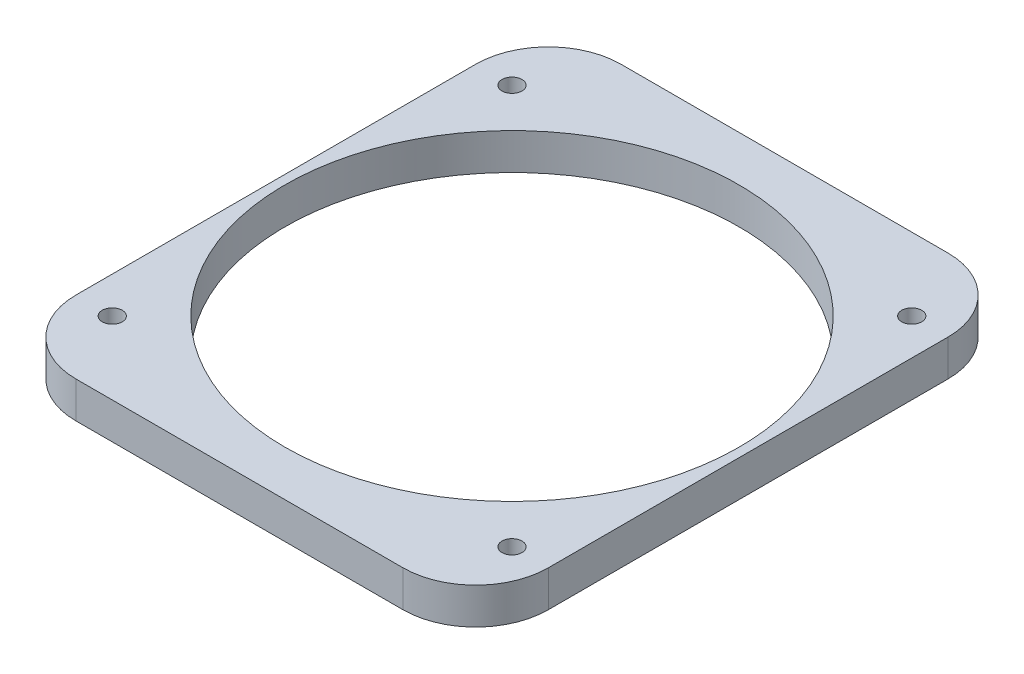
from build123d import *

# Parameters (mm, degrees)
SKETCH1_W           = 82.55
SKETCH1_H           = 95.25
SKETCH1_R           = 38.1
SKETCH1_R_2         = 1.75
BOSS_EXTRUDE1_DEPTH = 6.35
FILLET1_R           = 12.7
SKETCH2_R           = 39.6875
SKETCH2_R_2         = 38.1
CUT_EXTRUDE1_DEPTH  = 7.35


with BuildPart() as part:
    # Sketch1 → Boss-Extrude1 (new body)
    with BuildSketch(Plane(origin=(0, 0, 0), x_dir=(1, 0, 0), z_dir=(0, 1, 0))):
        Rectangle(SKETCH1_W, SKETCH1_H)
        Circle(SKETCH1_R, mode=Mode.SUBTRACT)
        with Locations((-34.925, 34.925)):
            Circle(SKETCH1_R_2, mode=Mode.SUBTRACT)
        with Locations((-34.925, -34.925)):
            Circle(SKETCH1_R_2, mode=Mode.SUBTRACT)
        with Locations((34.925, -34.925)):
            Circle(SKETCH1_R_2, mode=Mode.SUBTRACT)
        with Locations((34.925, 34.925)):
            Circle(SKETCH1_R_2, mode=Mode.SUBTRACT)
    extrude(amount=BOSS_EXTRUDE1_DEPTH)

    # Fillet1
    fillet1_edges = [part.edges().sort_by_distance(p)[0] for p in [
        (-41.275, 3.175, -47.625),
        (41.275, 3.175, -47.625),
        (41.275, 3.175, 47.625),
        (-41.275, 3.175, 47.625),
    ]]
    fillet(fillet1_edges, radius=FILLET1_R)

    # Sketch2 → Cut-Extrude1 (cut, through all)
    with BuildSketch(Plane(origin=(0, 6.35, 0), x_dir=(1, 0, 0), z_dir=(0, 1, 0))):
        Circle(SKETCH2_R)
        Circle(SKETCH2_R_2, mode=Mode.SUBTRACT)
    extrude(amount=-CUT_EXTRUDE1_DEPTH, mode=Mode.SUBTRACT)


solid = part.part
